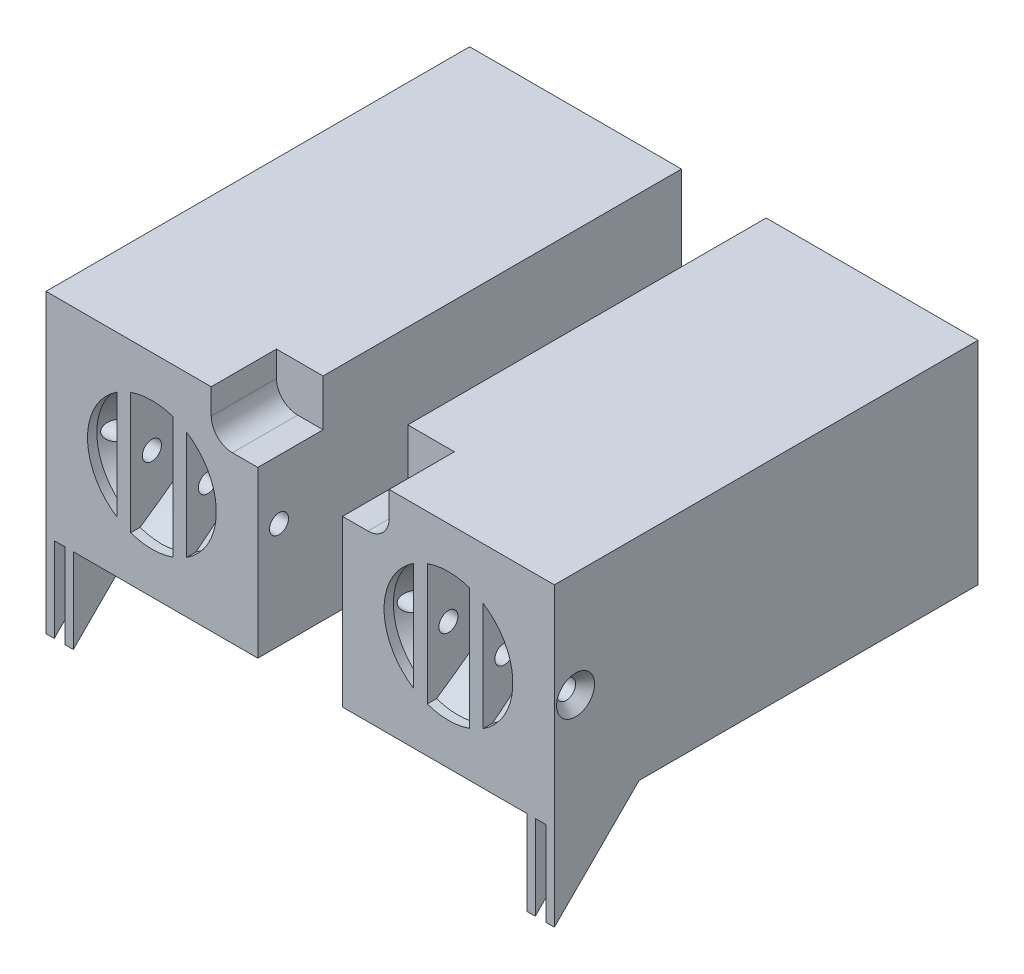
from build123d import *

# Parameters (mm, degrees)
CROQUIS1_W                                           = 50
CROQUIS1_H                                           = 50
CROQUIS1_R                                           = 2
SALIENTE_EXTRUIR2_DEPTH                              = 100
CROQUIS4_W                                           = 3.2
CROQUIS4_H                                           = 40
SALIENTE_EXTRUIR5_DEPTH                              = 10.2
CROQUIS8_R                                           = 4
CORTAR_EXTRUIR3_DEPTH                                = 87.4
CORTAR_EXTRUIR2_START                                = -50
CROQUIS7_R                                           = 2
CORTAR_EXTRUIR2_DEPTH                                = 50
REFRENTADO_PARA_TORNILLO_TAP_N_CON_CABEZ_D           = 4.5
REFRENTADO_PARA_TORNILLO_TAP_N_CON_CABEZ_CSINK_D     = 8.96
REFRENTADO_PARA_TORNILLO_TAP_N_CON_CABEZ_CSINK_ANGLE = 90
SALIENTE_EXTRUIR6_DEPTH                              = 1.95
SALIENTE_EXTRUIR7_START                              = -4.5
SALIENTE_EXTRUIR7_DEPTH                              = 1.95
CORTAR_EXTRUIR4_DEPTH                                = 15.4


with BuildPart() as part:
    # Croquis1 → Saliente-Extruir2 (new body)
    with BuildSketch(Plane.XY):
        Rectangle(CROQUIS1_W, CROQUIS1_H)
        Circle(CROQUIS1_R, mode=Mode.SUBTRACT)
    extrude(amount=SALIENTE_EXTRUIR2_DEPTH)

    # Croquis2 → Cortar-Revolución1 (revolve, cut)
    with BuildSketch(Plane(origin=(0, 0, 0), x_dir=(0, 0, -1), z_dir=(1, 0, 0))):
        Polygon((-100, 15.2), (-100, 0), (-89.8, 0), (-89.8, 10), (-97.8, 15.2), align=None)
    revolve(axis=Axis((0, 0, 100), (0, 0, -1)), mode=Mode.SUBTRACT)

    # Croquis4 → Saliente-Extruir5 (add)
    with BuildSketch(Plane.XY.offset(100)):
        with Locations((-6.6, 0)):
            Rectangle(CROQUIS4_W, CROQUIS4_H)
        with Locations((6.6, 0)):
            Rectangle(CROQUIS4_W, CROQUIS4_H)
    extrude(amount=-SALIENTE_EXTRUIR5_DEPTH)

    # Croquis8 → Cortar-Extruir3 (cut)
    with BuildSketch(Plane.XY.offset(89.8)):
        Circle(CROQUIS8_R)
    extrude(amount=-CORTAR_EXTRUIR3_DEPTH, mode=Mode.SUBTRACT)

    # Croquis7 → Cortar-Extruir2 (cut)
    with BuildSketch(Plane.ZY.offset(25).offset(CORTAR_EXTRUIR2_START)):
        with Locations((95, 0)):
            Circle(CROQUIS7_R)
    extrude(amount=CORTAR_EXTRUIR2_DEPTH, mode=Mode.SUBTRACT)

    # Refrentado para tornillo tapón con cabeza plana de clavija de M41 (through all)
    with Locations(Plane.ZY.offset(25)):
        with Locations((95, 0)):
            CounterSinkHole(REFRENTADO_PARA_TORNILLO_TAP_N_CON_CABEZ_D / 2, REFRENTADO_PARA_TORNILLO_TAP_N_CON_CABEZ_CSINK_D / 2, counter_sink_angle=REFRENTADO_PARA_TORNILLO_TAP_N_CON_CABEZ_CSINK_ANGLE)

    # Croquis12 → Saliente-Extruir6 (add)
    with BuildSketch(Plane.ZY.offset(25)):
        Polygon((100, -25), (80, -25), (100, -45), align=None)
    extrude(amount=-SALIENTE_EXTRUIR6_DEPTH)

    # Croquis12_2 → Saliente-Extruir7 (add)
    with BuildSketch(Plane.ZY.offset(25).offset(SALIENTE_EXTRUIR7_START)):
        Polygon((100, -25), (80, -25), (100, -45), align=None)
    extrude(amount=-SALIENTE_EXTRUIR7_DEPTH)

    # Croquis13 → Cortar-Extruir4 (cut)
    with BuildSketch(Plane.XY.offset(100)):
        with BuildLine():
            Line((25, 25), (25, 14))
            Line((25, 14), (19, 14))
            ThreePointArc((19, 14), (15.464466094, 15.464466094), (14, 19))
            Line((14, 19), (14, 25))
            Line((14, 25), (25, 25))
        make_face()
    extrude(amount=-CORTAR_EXTRUIR4_DEPTH, mode=Mode.SUBTRACT)


with BuildPart() as body_2:
    # Simetría3: mirrored copy
    add(part.part.mirror(Plane(origin=(35, 0, 0), x_dir=(0, 0, 1), z_dir=(1, 0, 0))))


solid = Compound([part.part, body_2.part])
